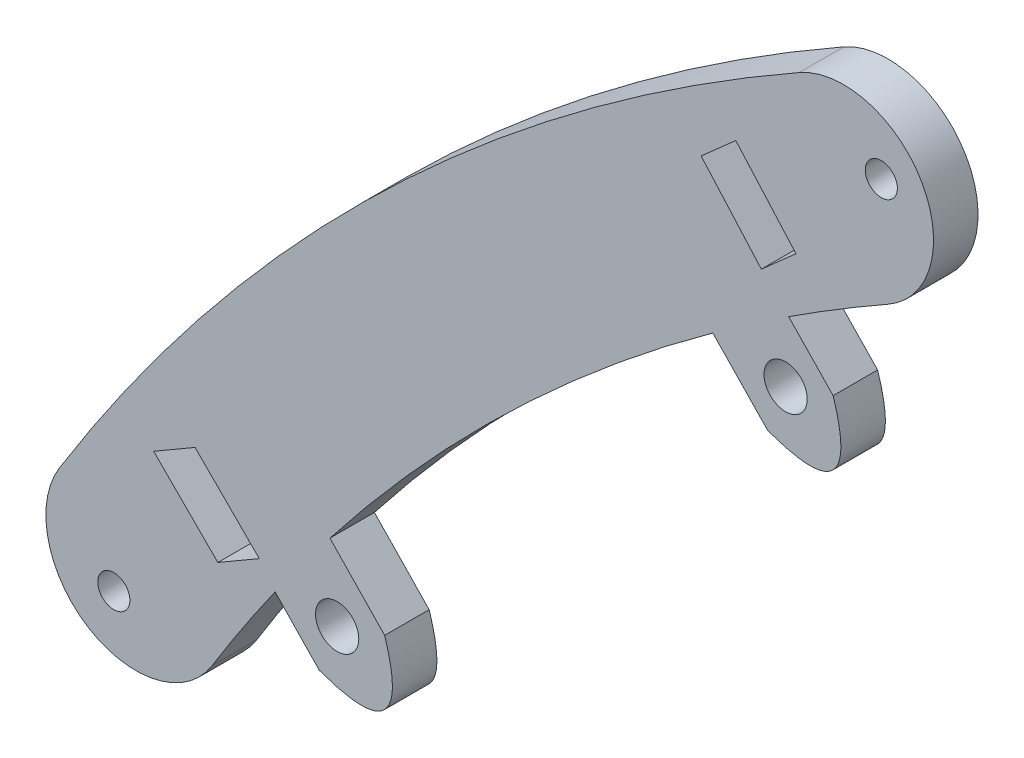
from build123d import *

# Parameters (mm, degrees)
SKETCH1_R           = 3.0861
SKETCH1_R_2         = 2.29235
BOSS_EXTRUDE1_DEPTH = 6.35


with BuildPart() as part:
    # Sketch1 → Boss-Extrude1 (new body)
    with BuildSketch(Plane.XY):
        with BuildLine():
            Line((9.317684399, -23.927461165), (15.621766017, -30.474222957))
            add(Edge.make_bspline(
                [(15.621766017, -30.474222957), (29.448816856, -35.495722543), (24.952941844, -21.488942011)],
                knots=[0, 0, 0, 1, 1, 1], degree=2))
            Line((24.952941844, -21.488942011), (17.141687262, -13.376987542))
            ThreePointArc((17.141687262, -13.376987542), (42.59986543, 14.894415901), (71.784823307, 39.299934171))
            Line((71.784823307, 39.299934171), (79.625725522, 31.157190761))
            add(Edge.make_bspline(
                [(79.625725522, 31.157190761), (93.452776362, 26.135691176), (88.956901349, 40.142471708)],
                knots=[0, 0, 0, 1, 1, 1], degree=2))
            Line((88.956901349, 40.142471708), (82.612726668, 46.730869976))
            ThreePointArc((82.612726668, 46.730869976), (89.632476194, 51.148612181), (96.784823972, 55.348284892))
            ThreePointArc((96.784823972, 55.348284892), (101.62072272, 72.831932717), (84.137074895, 77.667831466))
            ThreePointArc((84.137074895, 77.667831466), (24.914787096, 33.479112567), (-21.478374368, -24.032597715))
            ThreePointArc((-21.478374368, -24.032597715), (-17.306021838, -41.68636027), (0.347740718, -37.51400774))
            ThreePointArc((0.347740718, -37.51400774), (4.730111543, -30.652996464), (9.317684399, -23.927461165))
        make_face()
        with Locations((18.173165644, -23.786006993)):
            Circle(SKETCH1_R, mode=Mode.SUBTRACT)
        with Locations((95.832484441, 70.337620248)):
            Circle(SKETCH1_R_2, mode=Mode.SUBTRACT)
        with Locations((-13.699424668, -35.344042378)):
            Circle(SKETCH1_R_2, mode=Mode.SUBTRACT)
        Polygon((-8.010879952, -15.218201264), (-2.100930482, -11.788684368), (7.060562914, -20.950177765), (1.150613445, -24.379694661), align=None, mode=Mode.SUBTRACT)
        Polygon((70.118447134, 60.342279832), (75.060785804, 64.722474401), (83.652705921, 55.027887008), (78.71036725, 50.647692439), align=None, mode=Mode.SUBTRACT)
        with Locations((82.177125837, 37.84540285)):
            Circle(SKETCH1_R, mode=Mode.SUBTRACT)
    extrude(amount=BOSS_EXTRUDE1_DEPTH)


solid = part.part
